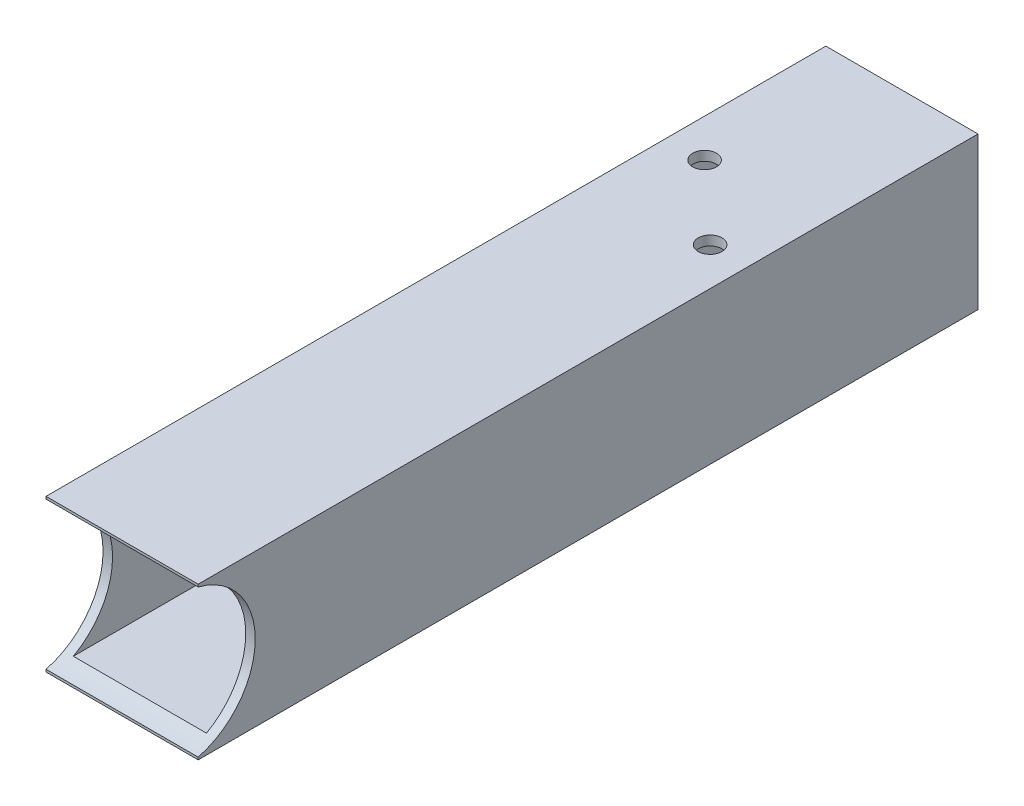
from build123d import *

# Parameters (mm, degrees)
SKETCH1_W           = 50.8
SKETCH1_H           = 50.8
SKETCH1_W_2         = 44.45
SKETCH1_H_2         = 44.45
BOSS_EXTRUDE1_DEPTH = 260.35
SKETCH2_R           = 25.4
CUT_EXTRUDE1_DEPTH  = 51.8
SKETCH3_R           = 3.96875
CUT_EXTRUDE2_DEPTH  = 51.8


with BuildPart() as part:
    # Sketch1 → Boss-Extrude1 (new body)
    with BuildSketch(Plane.XY):
        with Locations((25.4, 25.4)):
            Rectangle(SKETCH1_W, SKETCH1_H)
        with Locations((25.4, 25.4)):
            Rectangle(SKETCH1_W_2, SKETCH1_H_2, mode=Mode.SUBTRACT)
    extrude(amount=BOSS_EXTRUDE1_DEPTH)

    # Sketch2 → Cut-Extrude1 (cut, through all)
    with BuildSketch(Plane(origin=(50.8, 0, 0), x_dir=(0, 0, -1), z_dir=(1, 0, 0))):
        with Locations((-266.7, 25.4)):
            Circle(SKETCH2_R)
    extrude(amount=-CUT_EXTRUDE1_DEPTH, mode=Mode.SUBTRACT)

    # Sketch3 → Cut-Extrude2 (cut, through all)
    with BuildSketch(Plane.XZ):
        with Locations((38.1, 76.735833685)):
            Circle(SKETCH3_R)
        with Locations((12.7, 53.175)):
            Circle(SKETCH3_R)
    extrude(amount=-CUT_EXTRUDE2_DEPTH, mode=Mode.SUBTRACT)


solid = part.part
